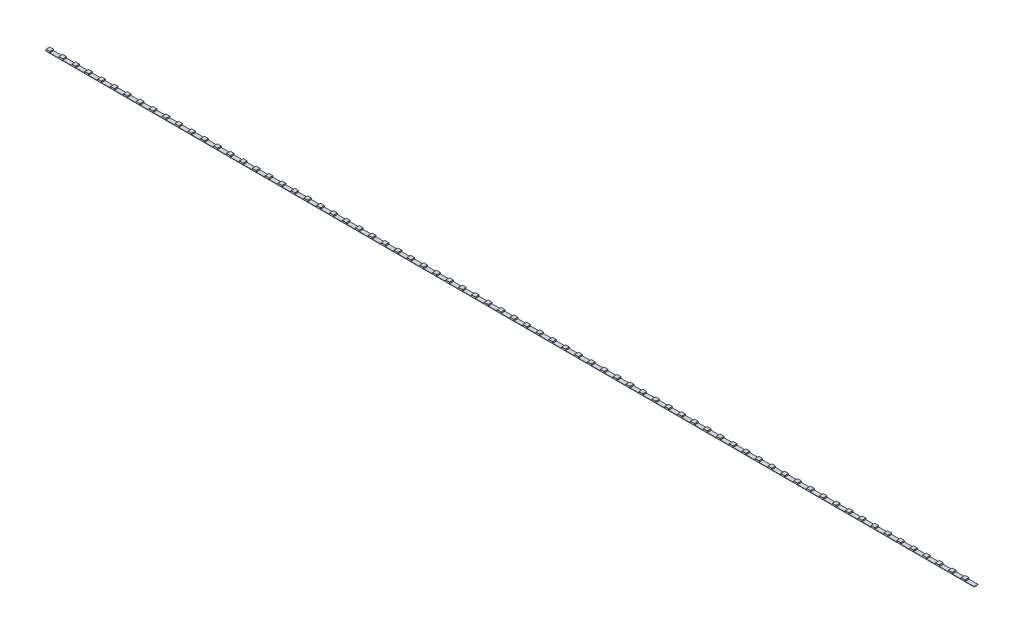
from build123d import *

# Parameters (mm, degrees)
SKETCH_1_W             = 1200
SKETCH_1_H             = 5
EXTRUDE_1_DEPTH        = 0.5
SKETCH_2_W             = 5
SKETCH_2_H             = 5
EXTRUDE_2_DEPTH        = 1.7
PATTERN_LINEAR_1_COUNT = 72
PATTERN_LINEAR_1_PITCH = 16.666666667


with BuildPart() as part:
    # 草图1 → 凸台-拉伸1 (new body)
    with BuildSketch(Plane(origin=(0, 0, 0), x_dir=(1, 0, 0), z_dir=(0, 1, 0))):
        Rectangle(SKETCH_1_W, SKETCH_1_H)
    extrude(amount=EXTRUDE_1_DEPTH)

    # 草图2 → 凸台-拉伸2 (add)
    with BuildSketch(Plane(origin=(0, 0.5, 0), x_dir=(1, 0, 0), z_dir=(0, 1, 0))):
        with Locations((-597.5, 0)):
            Rectangle(SKETCH_2_W, SKETCH_2_H)
    extrude_2 = extrude(amount=EXTRUDE_2_DEPTH)

    # 阵列(线性)1: 凸台-拉伸2 ×72
    with Locations(*[(i * PATTERN_LINEAR_1_PITCH, 0, 0) for i in range(1, PATTERN_LINEAR_1_COUNT)]):
        add(extrude_2)


solid = part.part
